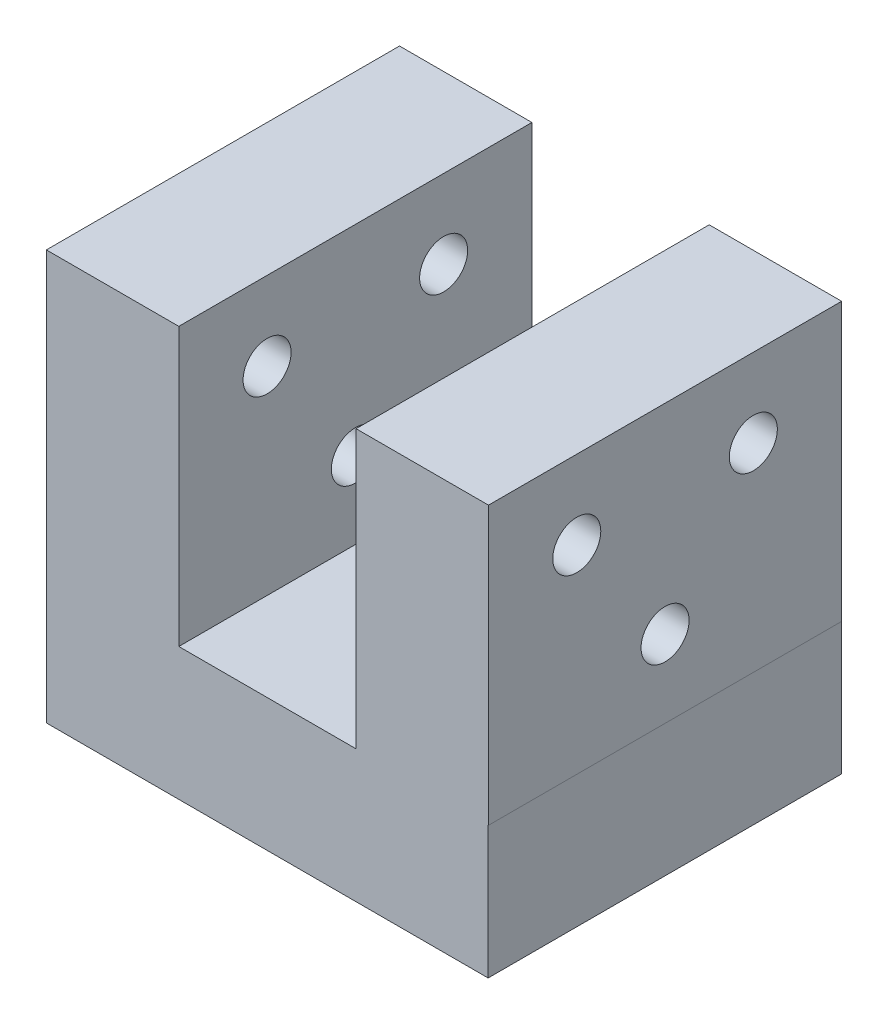
from build123d import *

# Parameters (mm, degrees)
SKETCH1_W                  = 31.75
SKETCH1_H                  = 25.4
BOSS_EXTRUDE1_DEPTH        = 9.525
M2_5_CLEARANCE_HOLE1_D     = 3.1
M2_5_CLEARANCE_HOLE1_DEPTH = 8.001
M2_5_CLEARANCE_HOLE1_TIP   = 0.931333959
SKETCH3_W                  = 9.525
SKETCH3_H                  = 19.942491079
BOSS_EXTRUDE2_DEPTH        = 25.4
F_4_CLEARANCE_HOLE1_D      = 3.4544
SKETCH9_W                  = 5.8975
SKETCH9_H                  = 5.8975
CUT_EXTRUDE1_DEPTH         = 1.09455
SKETCH10_W                 = 5.453
SKETCH10_H                 = 6.0499
CUT_EXTRUDE2_DEPTH         = 1.1771


with BuildPart() as part:
    # Sketch1 → Boss-Extrude1 (new body)
    with BuildSketch(Plane(origin=(0, 0, 0), x_dir=(1, 0, 0), z_dir=(0, 1, 0))):
        Rectangle(SKETCH1_W, SKETCH1_H)
    extrude(amount=BOSS_EXTRUDE1_DEPTH)

    # M2.5 Clearance Hole1
    with Locations(Plane(origin=(8, 0, -8), x_dir=(0, 0, -1), z_dir=(0, -1, 0))):
        with Locations((0, 0), (-16, 0), (-16, -16), (0, -16)):
            Hole(M2_5_CLEARANCE_HOLE1_D / 2, depth=M2_5_CLEARANCE_HOLE1_DEPTH)
            with Locations((0, 0, -(M2_5_CLEARANCE_HOLE1_DEPTH + M2_5_CLEARANCE_HOLE1_TIP / 2))):  # 118° drill point
                Cone(0, M2_5_CLEARANCE_HOLE1_D / 2, M2_5_CLEARANCE_HOLE1_TIP, mode=Mode.SUBTRACT)

    # Sketch3 → Boss-Extrude2 (add)
    with BuildSketch(Plane(origin=(0, 0, -12.7), x_dir=(-1, 0, 0), z_dir=(0, 0, -1))):
        with Locations((11.1379, 19.49624554)):
            Rectangle(SKETCH3_W, SKETCH3_H)
        with Locations((-11.1379, 19.49624554)):
            Rectangle(SKETCH3_W, SKETCH3_H)
    extrude(amount=-BOSS_EXTRUDE2_DEPTH)

    # #4 Clearance Hole1 (through all)
    with Locations(Plane(origin=(15.9004, 0, 0), x_dir=(0, 0, -1), z_dir=(1, 0, 0))):
        with Locations((0, 15.08125), (6.35, 23.8125), (-6.35, 23.8125)):
            Hole(F_4_CLEARANCE_HOLE1_D / 2)

    # Sketch9 → Cut-Extrude1 (cut, symmetric)
    with BuildSketch(Plane(origin=(11.1379, 0, 0), x_dir=(0, 0, -1), z_dir=(1, 0, 0))):
        with Locations((6.35, 23.8125)):
            Rectangle(SKETCH9_W, SKETCH9_H)
        with Locations((0, 15.08125)):
            Rectangle(SKETCH9_W, SKETCH9_H)
        with Locations((-6.35, 23.8125)):
            Rectangle(SKETCH9_W, SKETCH9_H)
    extrude(amount=CUT_EXTRUDE1_DEPTH, both=True, mode=Mode.SUBTRACT)

    # Sketch10 → Cut-Extrude2 (cut, symmetric)
    with BuildSketch(Plane(origin=(0, 4.7625, 0), x_dir=(-1, 0, 0), z_dir=(0, -1, 0))):
        with Locations((-8, 8)):
            Rectangle(SKETCH10_W, SKETCH10_H)
        with Locations((8, 8)):
            Rectangle(SKETCH10_W, SKETCH10_H)
        with Locations((8, -8)):
            Rectangle(SKETCH10_W, SKETCH10_H)
        with Locations((-8, -8)):
            Rectangle(SKETCH10_W, SKETCH10_H)
    extrude(amount=CUT_EXTRUDE2_DEPTH, both=True, mode=Mode.SUBTRACT)


solid = part.part
